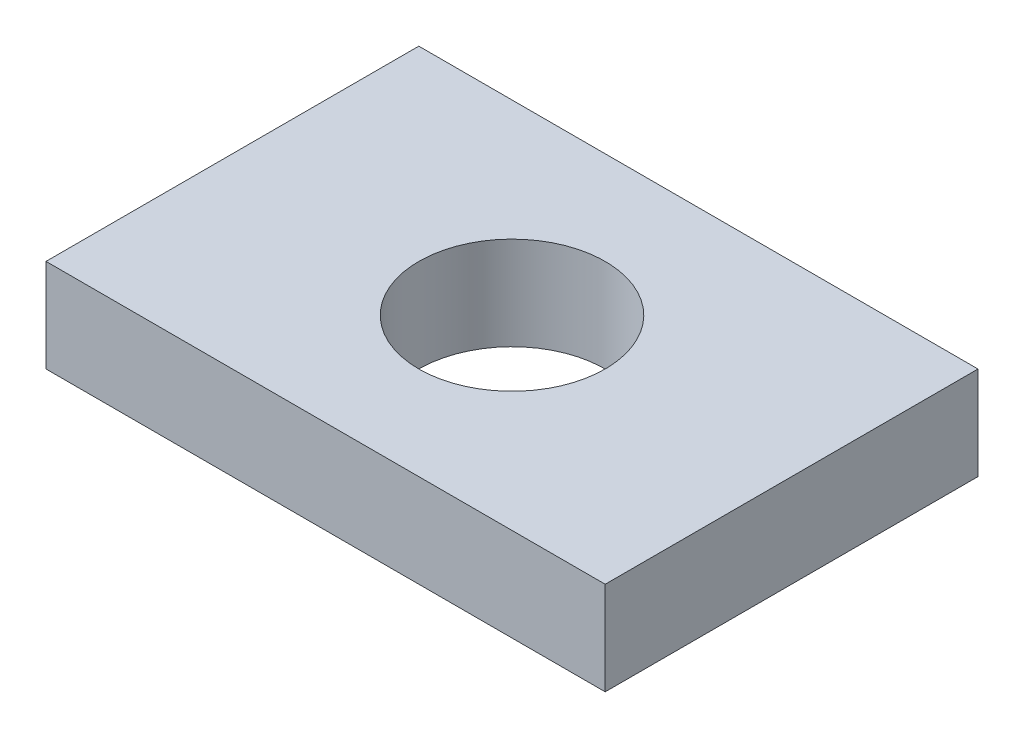
from build123d import *

# Parameters (mm, degrees)
SKETCH1_W           = 38.1
SKETCH1_H           = 25.4
SKETCH1_R           = 6.35
BOSS_EXTRUDE1_DEPTH = 6.35


with BuildPart() as part:
    # Sketch1 → Boss-Extrude1 (new body)
    with BuildSketch(Plane(origin=(0, 0, 0), x_dir=(1, 0, 0), z_dir=(0, 1, 0))):
        with Locations((19.05, 12.7)):
            Rectangle(SKETCH1_W, SKETCH1_H)
        with Locations((19.05, 12.7)):
            Circle(SKETCH1_R, mode=Mode.SUBTRACT)
    extrude(amount=BOSS_EXTRUDE1_DEPTH)


solid = part.part
